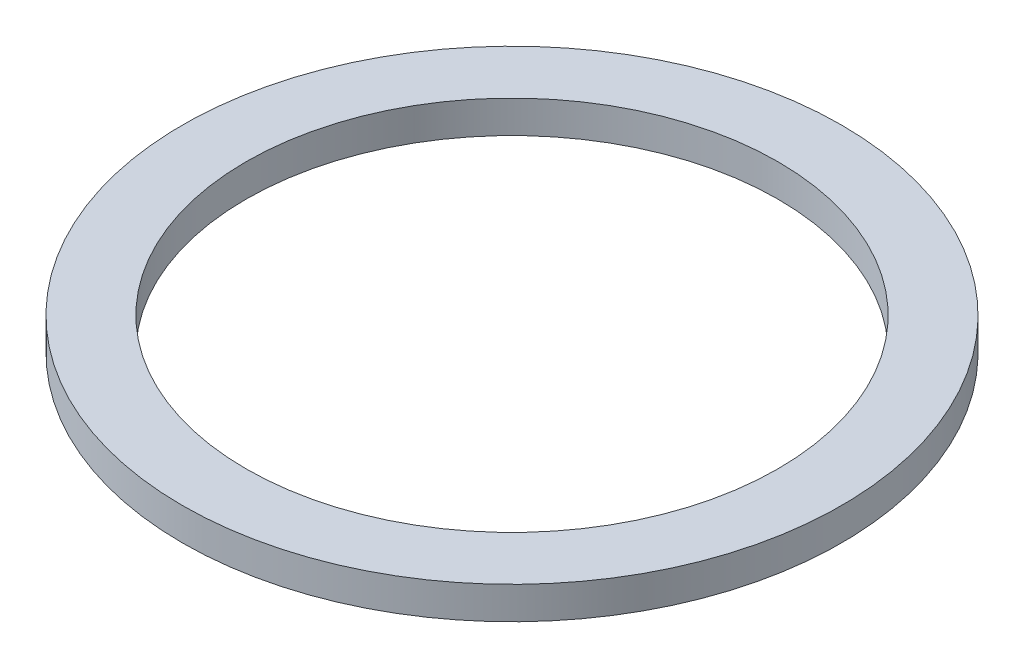
from build123d import *

# Parameters (mm, degrees)
SKETCH_1_W = 4.9
SKETCH_1_H = 2.5


with BuildPart() as part:
    # 草图1 → 旋转1 (revolve)
    with BuildSketch(Plane.XY, mode=Mode.PRIVATE) as revolve_1_sk:
        with Locations((22.95, 1.25)):
            Rectangle(SKETCH_1_W, SKETCH_1_H)
    revolve(revolve_1_sk.sketch.rotate(Axis((0, 77.144142266, 0), (0, -1, 0)), 90), axis=Axis((0, 77.144142266, 0), (0, -1, 0)))  # turned: the seam where the file's is


solid = part.part
